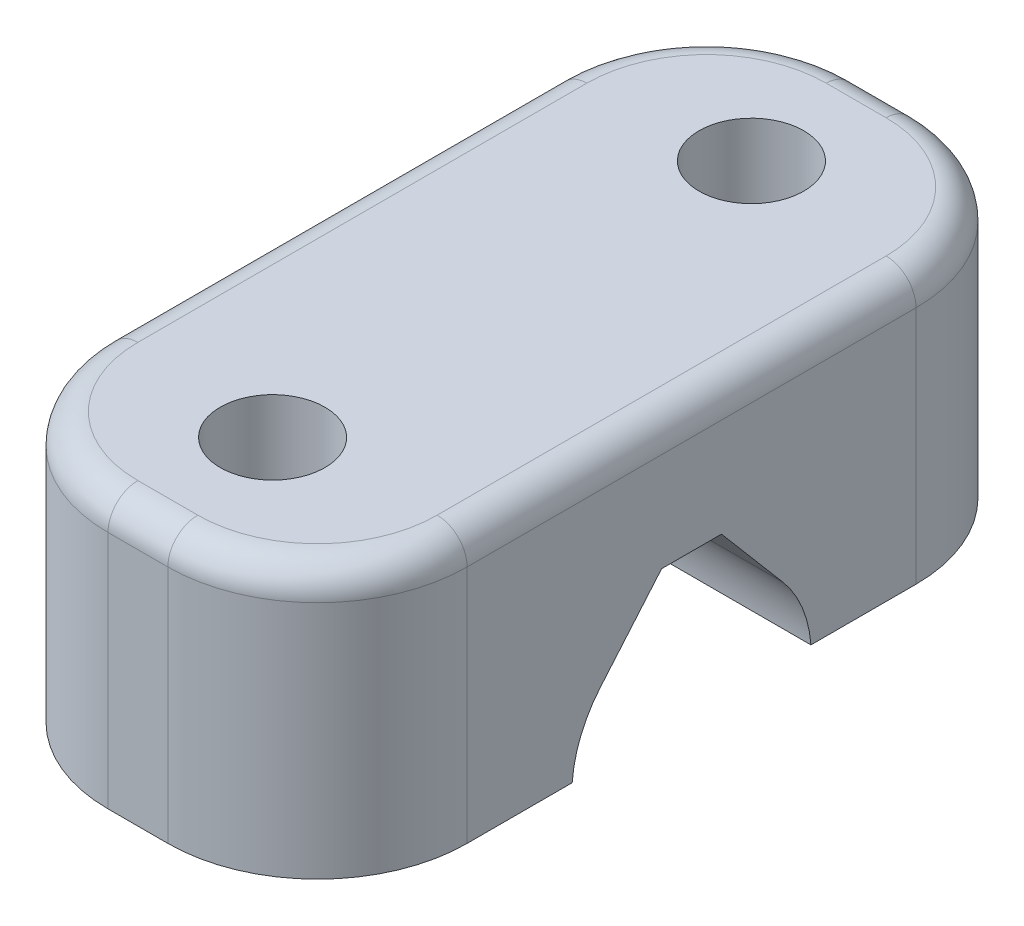
from build123d import *

# Parameters (mm, degrees)
CROQUIS1_W              = 12
CROQUIS1_H              = 25
SALIENTE_EXTRUIR1_DEPTH = 9
CORTAR_EXTRUIR1_DEPTH   = 13
CROQUIS4_R              = 1.75
CORTAR_EXTRUIR2_DEPTH   = 10
REDONDEO1_R             = 5
REDONDEO2_R             = 1


with BuildPart() as part:
    # Croquis1 → Saliente-Extruir1 (new body)
    with BuildSketch(Plane(origin=(0, 0, 0), x_dir=(1, 0, 0), z_dir=(0, 1, 0))):
        with Locations((6, 0)):
            Rectangle(CROQUIS1_W, CROQUIS1_H)
    extrude(amount=SALIENTE_EXTRUIR1_DEPTH)

    # Croquis3 → Cortar-Extruir1 (cut, through all)
    with BuildSketch(Plane(origin=(0, 0, 0), x_dir=(0, 0, -1), z_dir=(1, 0, 0))):
        with BuildLine():
            Line((-3.047905892, 2.290418822), (-1, 4.7))
            Line((-1, 4.7), (1, 4.7))
            Line((1, 4.7), (3.047905892, 2.290418822))
            ThreePointArc((3.047905892, 2.290418822), (0, -4.3), (-3.047905892, 2.290418822))
        make_face()
    extrude(amount=CORTAR_EXTRUIR1_DEPTH, mode=Mode.SUBTRACT)

    # Croquis4 → Cortar-Extruir2 (cut, through all)
    with BuildSketch(Plane.XZ):
        with Locations((6, 8)):
            Circle(CROQUIS4_R)
        with Locations((6, -8)):
            Circle(CROQUIS4_R)
    extrude(amount=-CORTAR_EXTRUIR2_DEPTH, mode=Mode.SUBTRACT)

    # Redondeo1
    redondeo1_edges = [part.edges().sort_by_distance(p)[0] for p in [
        (0, 4.5, -12.5),
        (12, 4.5, -12.5),
        (12, 4.5, 12.5),
        (0, 4.5, 12.5),
    ]]
    fillet(redondeo1_edges, radius=REDONDEO1_R)

    # Redondeo2
    redondeo2_edges = [part.edges().sort_by_distance(p)[0] for p in [
        (0, 9, 0),
        (6, 9, -12.5),
        (6, 9, 12.5),
        (12, 9, 0),
        (1.464466094, 9, 11.035533906),
        (10.535533906, 9, 11.035533906),
        (10.535533906, 9, -11.035533906),
        (1.464466094, 9, -11.035533906),
    ]]
    fillet(redondeo2_edges, radius=REDONDEO2_R)


solid = part.part
